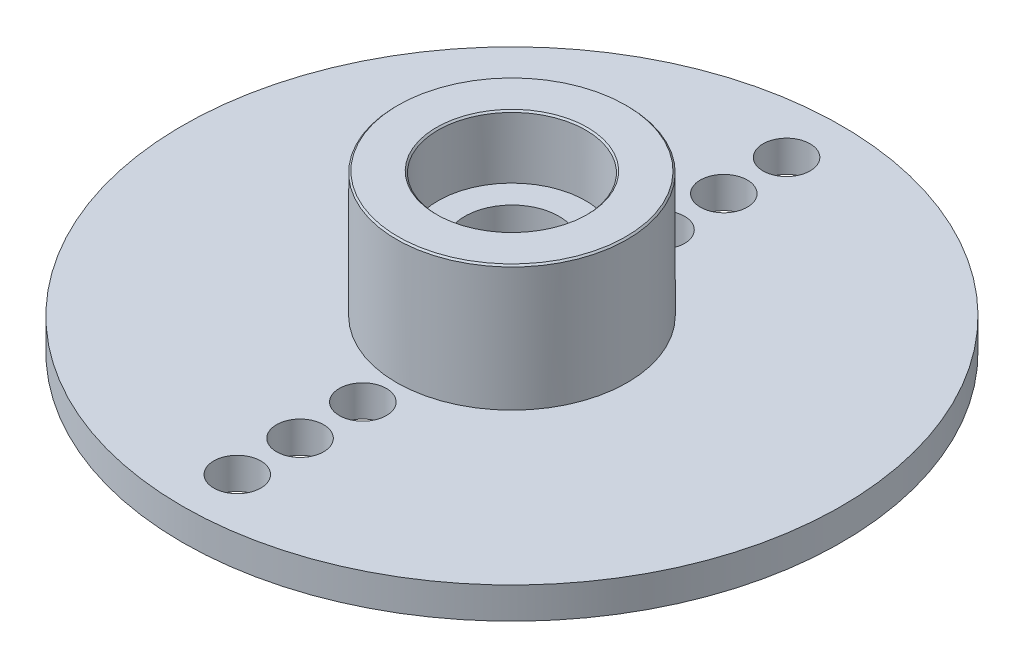
from build123d import *

# Parameters (mm, degrees)
SKETCH1_R           = 10.5
SKETCH1_R_2         = 0.75
BOSS_EXTRUDE2_DEPTH = 1
SKETCH2_R           = 3.67931812
SKETCH2_R_2         = 1.5
BOSS_EXTRUDE6_DEPTH = 5
SKETCH4_R           = 0.75
BOSS_EXTRUDE7_DEPTH = 1
SKETCH5_R           = 1.5
CUT_EXTRUDE2_DEPTH  = 0.5
SKETCH1_5_R         = 0.75
CUT_EXTRUDE3_DEPTH  = 6
SKETCH6_R           = 2.355
CUT_EXTRUDE4_DEPTH  = 2
CHAMFER1_SIZE       = 0.05


with BuildPart() as part:
    # Sketch1 → Boss-Extrude2 (new body)
    with BuildSketch(Plane(origin=(0, 0, 0), x_dir=(1, 0, 0), z_dir=(0, 1, 0))):
        Circle(SKETCH1_R)
        with Locations((0, 8.75)):
            Circle(SKETCH1_R_2, mode=Mode.SUBTRACT)
        with Locations((0, 6.75)):
            Circle(SKETCH1_R_2, mode=Mode.SUBTRACT)
        with Locations((0, 4.75)):
            Circle(SKETCH1_R_2, mode=Mode.SUBTRACT)
        with Locations((0, -4.75)):
            Circle(SKETCH1_R_2, mode=Mode.SUBTRACT)
        with Locations((0, -6.75)):
            Circle(SKETCH1_R_2, mode=Mode.SUBTRACT)
        with Locations((0, -8.75)):
            Circle(SKETCH1_R_2, mode=Mode.SUBTRACT)
        Circle(SKETCH1_R_2, mode=Mode.SUBTRACT)
    extrude(amount=BOSS_EXTRUDE2_DEPTH)

    # Sketch2 → Boss-Extrude6 (add)
    with BuildSketch(Plane.XZ):
        Circle(SKETCH2_R)
        Circle(SKETCH2_R_2, mode=Mode.SUBTRACT)
    extrude(amount=-BOSS_EXTRUDE6_DEPTH)

    # Sketch4 → Boss-Extrude7 (add)
    with BuildSketch(Plane.XZ):
        Circle(SKETCH4_R)
    extrude(amount=-BOSS_EXTRUDE7_DEPTH)

    # Sketch5 → Cut-Extrude2 (cut)
    with BuildSketch(Plane.XZ):
        Circle(SKETCH5_R)
    extrude(amount=-CUT_EXTRUDE2_DEPTH, mode=Mode.SUBTRACT)

    # Sketch1_5 → Cut-Extrude3 (cut, through all)
    with BuildSketch(Plane(origin=(0, 0, 0), x_dir=(1, 0, 0), z_dir=(0, 1, 0))):
        Circle(SKETCH1_5_R)
    extrude(amount=CUT_EXTRUDE3_DEPTH, mode=Mode.SUBTRACT)

    # Sketch6 → Cut-Extrude4 (cut)
    with BuildSketch(Plane(origin=(0, 5, 0), x_dir=(1, 0, 0), z_dir=(0, 1, 0))):
        Circle(SKETCH6_R)
    extrude(amount=-CUT_EXTRUDE4_DEPTH, mode=Mode.SUBTRACT)

    # Chamfer1
    chamfer1_edges = [part.edges().sort_by_distance(p)[0] for p in [
        (-3.67931812, 5, 0),
        (-2.355, 5, 0),
    ]]
    chamfer(chamfer1_edges, length=CHAMFER1_SIZE)


solid = part.part
